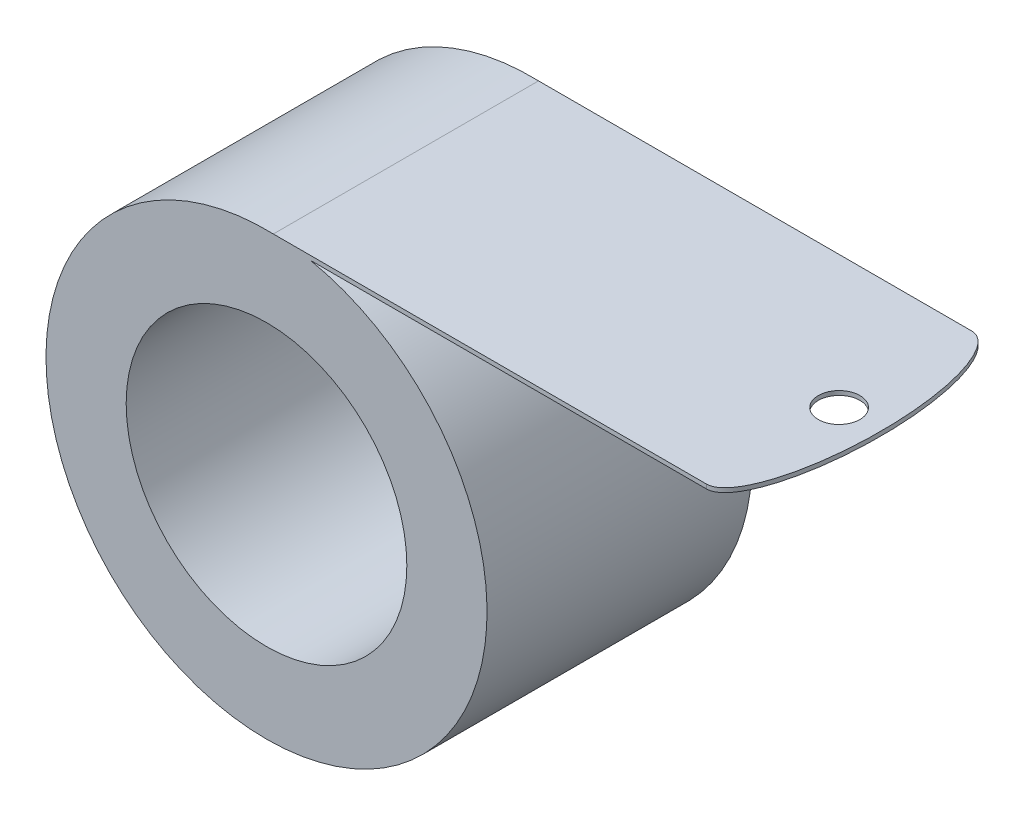
from build123d import *

# Parameters (mm, degrees)
SKETCH1_R           = 26.4033
SKETCH1_R_2         = 16.8021
BOSS_EXTRUDE1_DEPTH = 31.75
SKETCH2_R           = 2.4892
BOSS_EXTRUDE2_DEPTH = 0.508


with BuildPart() as part:
    # Sketch1 → Boss-Extrude1 (new body)
    with BuildSketch(Plane.XY):
        Circle(SKETCH1_R)
        Circle(SKETCH1_R_2, mode=Mode.SUBTRACT)
    extrude(amount=BOSS_EXTRUDE1_DEPTH)

    # Sketch2 → Boss-Extrude2 (add)
    with BuildSketch(Plane(origin=(0, 25.8826, 0), x_dir=(1, 0, 0), z_dir=(0, 1, 0))):
        with BuildLine():
            Line((0, -31.75), (0, 0))
            Line((0, 0), (52.681392922, 0))
            add(Edge.make_bspline(
                [(52.681392922, -31.75), (57.642158889, -31.75), (57.642158889, -15.875), (57.642158889, 0), (52.681392922, 0)],
                knots=[3.141592654, 3.141592654, 3.141592654, 4.71238898, 4.71238898, 6.283185307, 6.283185307, 6.283185307], degree=2, weights=[1, 0.707106781, 1, 0.707106781, 1]))
            Line((52.681392922, -31.75), (0, -31.75))
        make_face()
        with Locations((52.681392922, -15.875)):
            Circle(SKETCH2_R, mode=Mode.SUBTRACT)
    extrude(amount=BOSS_EXTRUDE2_DEPTH)


solid = part.part
